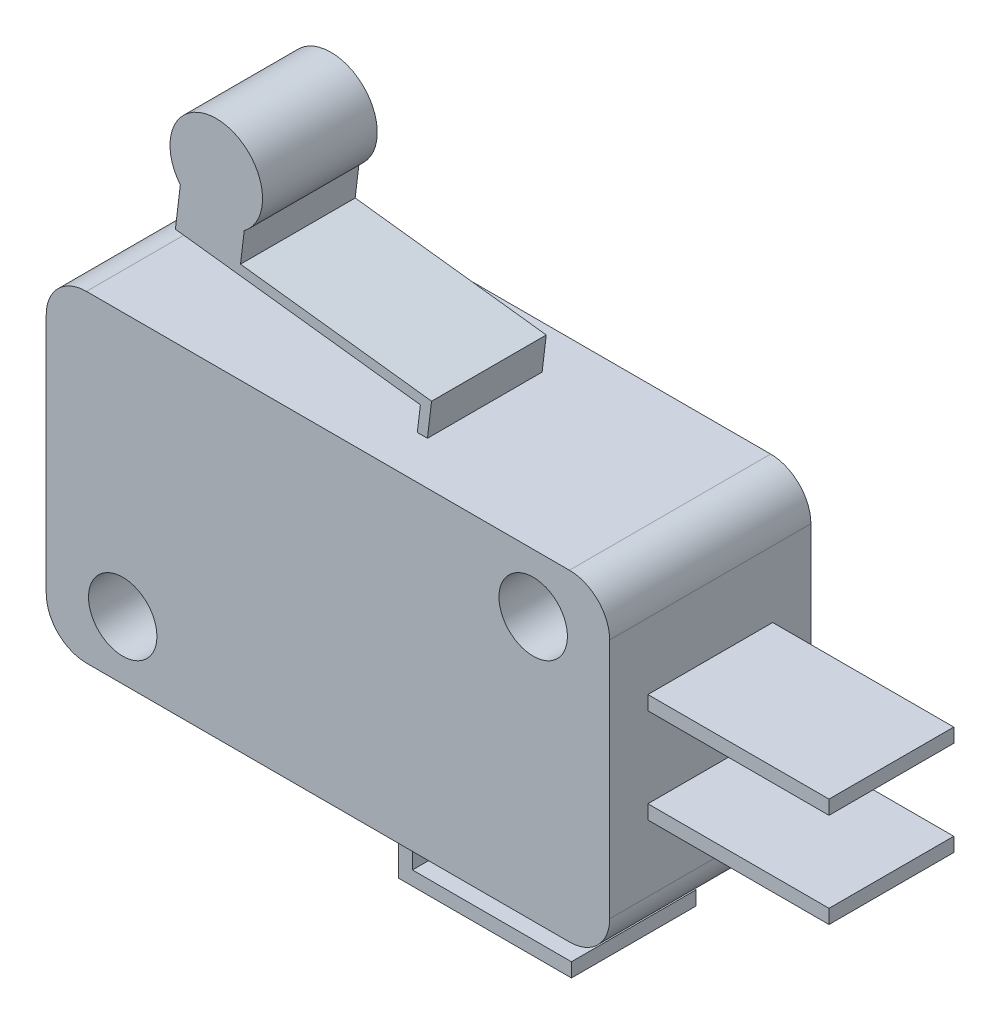
from build123d import *

# Parameters (mm, degrees)
SKETCH1_R           = 1.7
BOSS_EXTRUDE1_DEPTH = 5
SKETCH2_R           = 2.3
BOSS_EXTRUDE2_DEPTH = 2.85
SKETCH3_W           = 9
SKETCH3_H           = 0.7
BOSS_EXTRUDE3_DEPTH = 3.1


with BuildPart() as part:
    # Sketch1 → Boss-Extrude1 (new body, symmetric)
    with BuildSketch(Plane.XY):
        with BuildLine():
            Line((2, 0), (26, 0))
            ThreePointArc((26, 0), (27.414213562, 0.585786438), (28, 2))
            Line((28, 2), (28, 14))
            ThreePointArc((28, 14), (27.414213562, 15.414213562), (26, 16))
            Line((26, 16), (2, 16))
            ThreePointArc((2, 16), (0.585786438, 15.414213562), (0, 14))
            Line((0, 14), (0, 2))
            ThreePointArc((0, 2), (0.585786438, 0.585786438), (2, 0))
        make_face()
        with Locations((3.8, 2.9)):
            Circle(SKETCH1_R, mode=Mode.SUBTRACT)
        with Locations((24.2, 13.1)):
            Circle(SKETCH1_R, mode=Mode.SUBTRACT)
    extrude(amount=BOSS_EXTRUDE1_DEPTH, both=True)

    # Sketch2 → Boss-Extrude2 (add, symmetric)
    with BuildSketch(Plane.XY):
        with BuildLine():
            Line((16.443613757, 17.263612158), (15.919001734, 12.923377494))
            Line((15.919001734, 12.923377494), (16.415388776, 12.863378293))
            Line((16.415388776, 12.863378293), (17, 17.7))
            Line((17, 17.7), (7.504443651, 18.847745091))
            Line((7.504443651, 18.847745091), (7.690168637, 20.384290169))
            ThreePointArc((7.690168637, 20.384290169), (6.024003677, 19.933239209), (4.513291566, 20.768285054))
            Line((4.513291566, 20.768285054), (4.267567379, 18.735352933))
            Line((4.267567379, 18.735352933), (16.443613757, 17.263612158))
        make_face()
        with Locations((6.3, 22.216619605)):
            Circle(SKETCH2_R)
    extrude(amount=BOSS_EXTRUDE2_DEPTH, both=True)

    # Sketch3 → Boss-Extrude3 (add, symmetric)
    with BuildSketch(Plane.XY):
        with Locations((32.5, 10.35)):
            Rectangle(SKETCH3_W, SKETCH3_H)
        with Locations((32.5, 5.65)):
            Rectangle(SKETCH3_W, SKETCH3_H)
        Polygon((15.6, 0), (15.6, -3.4), (24.2, -3.4), (24.2, -2.7), (16.3, -2.7), (16.3, 0), align=None)
    extrude(amount=BOSS_EXTRUDE3_DEPTH, both=True)


solid = part.part
